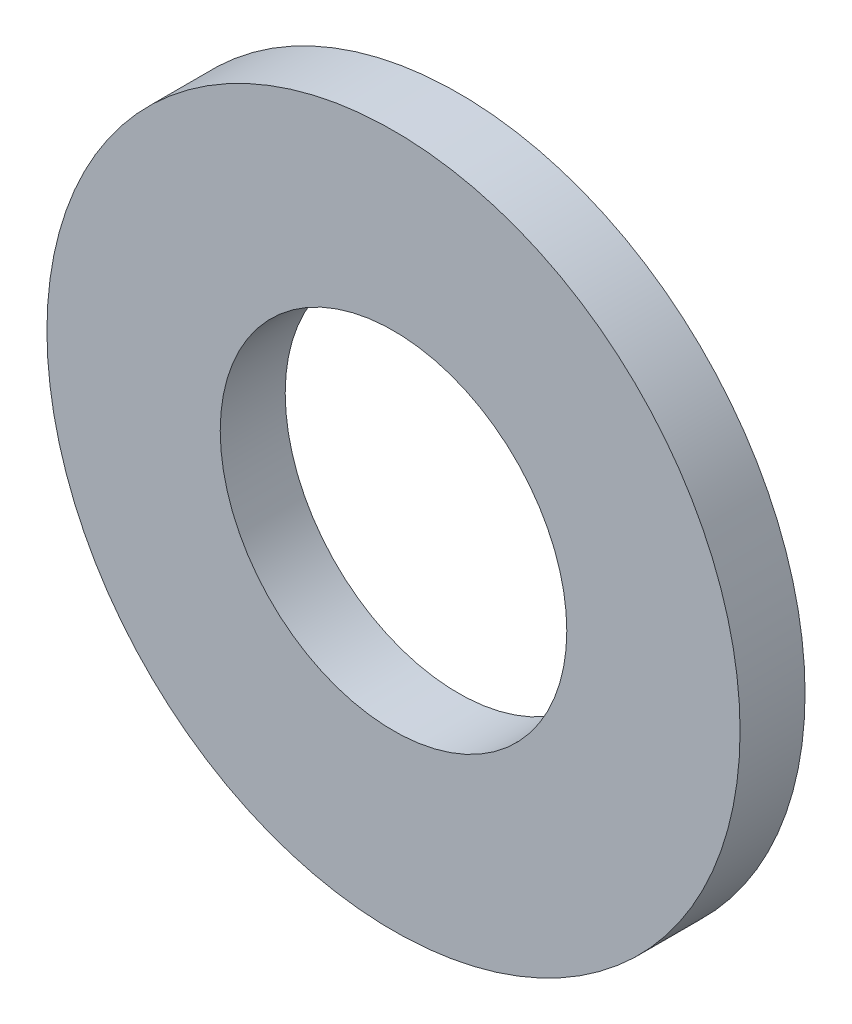
from build123d import *

# Parameters (mm, degrees)
SKETCH_1_R      = 8
SKETCH_1_R_2    = 4
EXTRUDE_1_DEPTH = 1.5


with BuildPart() as part:
    # 草图1 → 凸台-拉伸1 (new body)
    with BuildSketch(Plane.XY):
        Circle(SKETCH_1_R)
        Circle(SKETCH_1_R_2, mode=Mode.SUBTRACT)
    extrude(amount=EXTRUDE_1_DEPTH)


solid = part.part
